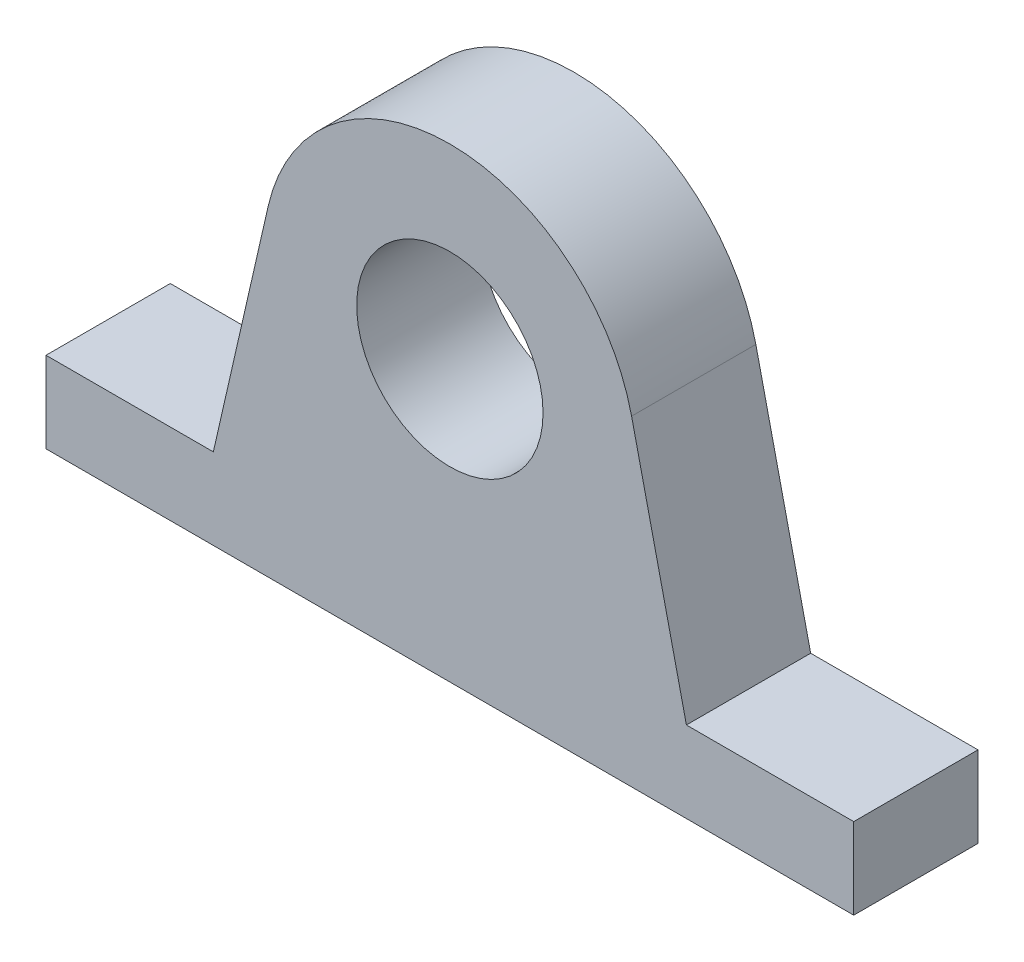
from build123d import *

# Parameters (mm, degrees)
ESBO_O1_R                = 3
RESSALTO_EXTRUS_O1_DEPTH = 4


with BuildPart() as part:
    # Esboço1 → Ressalto-extrusão1 (new body)
    with BuildSketch(Plane.XY):
        with BuildLine():
            Line((-8.209602621, 0), (8.209602621, 0))
            Line((8.209602621, 0), (13, 0))
            Line((13, 0), (13, 2.609213558))
            Line((13, 2.609213558), (7.613786386, 2.609213558))
            Line((7.613786386, 2.609213558), (5.849431135, 10.335722798))
            ThreePointArc((5.849431135, 10.335722798), (0, 15), (-5.849431135, 10.335722798))
            Line((-5.849431135, 10.335722798), (-7.613786386, 2.609213558))
            Line((-7.613786386, 2.609213558), (-13, 2.609213558))
            Line((-13, 2.609213558), (-13, 0))
            Line((-13, 0), (-8.209602621, 0))
        make_face()
        with Locations((0, 9)):
            Circle(ESBO_O1_R, mode=Mode.SUBTRACT)
    extrude(amount=RESSALTO_EXTRUS_O1_DEPTH)


solid = part.part
